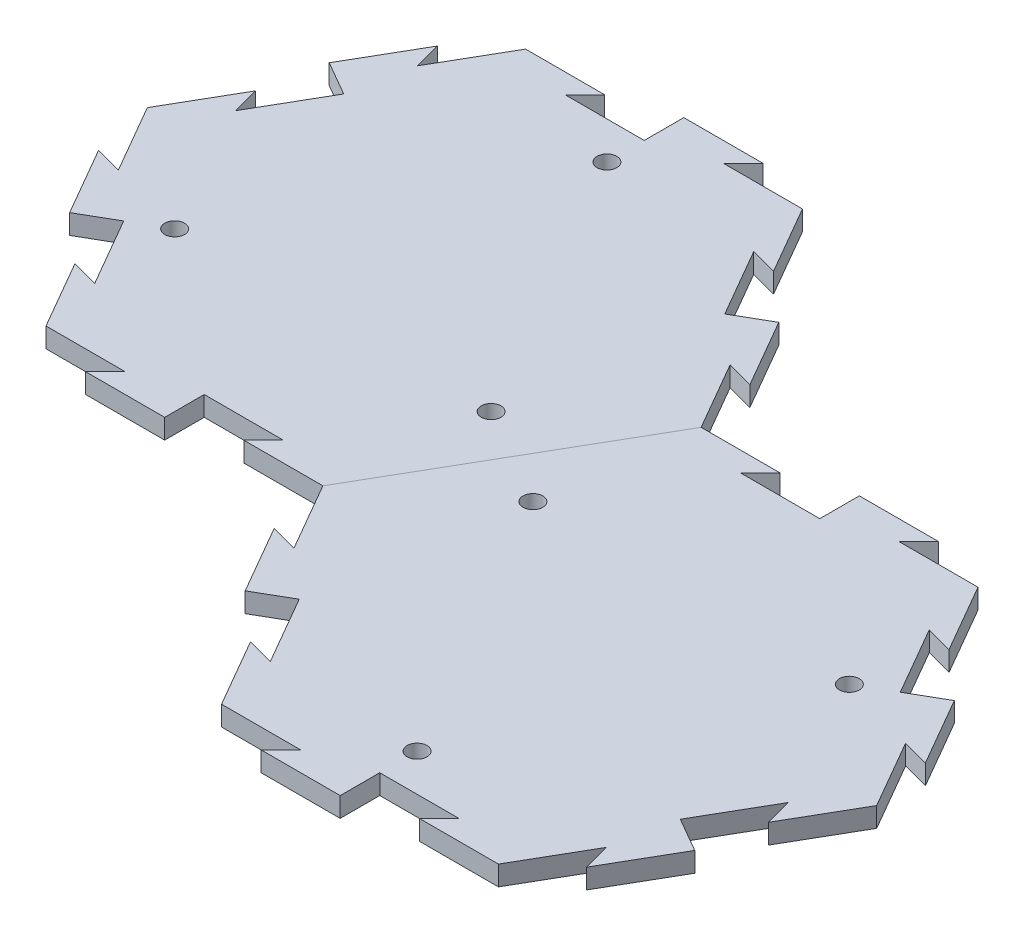
from build123d import *

# Parameters (mm, degrees)
BOSS_EXTRUDE1_DEPTH = 6.35
SKETCH9_R           = 3.175
CUT_EXTRUDE3_DEPTH  = 118.774954893
CIRPATTERN6_COUNT   = 3
CUT_EXTRUDE4_DEPTH  = 271.453350876
BOSS_EXTRUDE4_DEPTH = 6.35
CIRPATTERN7_COUNT   = 6
CUT_EXTRUDE5_DEPTH  = 271.453350876
BOSS_EXTRUDE5_DEPTH = 6.35
CIRPATTERN8_COUNT   = 6


with BuildPart() as part:
    # Sketch1 → Boss-Extrude1 (new body)
    with BuildSketch(Plane(origin=(0, 0, 0), x_dir=(1, 0, 0), z_dir=(0, 1, 0))):
        Polygon((88.9, 0), (44.45, 76.989658396), (-44.45, 76.989658396), (-88.9, 0), (-44.45, -76.989658396), (44.45, -76.989658396), align=None)
    extrude(amount=-BOSS_EXTRUDE1_DEPTH)

    # Sketch9 → Cut-Extrude3 (cut, through all)
    with BuildSketch(Plane(origin=(0, 0, 0), x_dir=(1, 0, 0), z_dir=(0, 1, 0))):
        with Locations((-50.8, -29.329393675)):
            Circle(SKETCH9_R)
    cut_extrude3 = extrude(amount=-CUT_EXTRUDE3_DEPTH, mode=Mode.SUBTRACT)

    # CirPattern6: Cut-Extrude3 ×3 about axis
    cirpattern6_axis = Axis((0, 0, 0), (0, 1, 0))
    for i in range(1, CIRPATTERN6_COUNT):
        add(cut_extrude3.rotate(cirpattern6_axis, i * 360 / CIRPATTERN6_COUNT), mode=Mode.SUBTRACT)


with BuildPart() as body_2:
    # Mirror3: mirrored copy
    add(part.part.mirror(Plane(origin=(44.45, -6.35, 76.989658396), x_dir=(-0.49999999999999495, 0, 0.8660254037844416), z_dir=(0.8660254037844416, 0, 0.49999999999999495))))

    # Sketch13 → Cut-Extrude5 (cut, through all)
    with BuildSketch(Plane(origin=(0, 0, 0), x_dir=(1, 0, 0), z_dir=(0, 1, 0))):
        Polygon((190.5, -21.997045256), (181.825738686, -19.672783942), (194.525738686, -41.669829198), (200.025, -38.494829198), align=None)
    cut_extrude5 = extrude(amount=-CUT_EXTRUDE5_DEPTH, mode=Mode.SUBTRACT)

    # Sketch14 → Boss-Extrude5 (add)
    with BuildSketch(Plane(origin=(0, 0, 0), x_dir=(1, 0, 0), z_dir=(0, 1, 0))):
        Polygon((200.025, -38.494829198), (205.524261314, -35.319829198), (218.224261314, -57.316874454), (209.55, -54.99261314), align=None)
    boss_extrude5 = extrude(amount=-BOSS_EXTRUDE5_DEPTH)

    # CirPattern8: Cut-Extrude5, Boss-Extrude5 ×6 about axis, 1 skipped
    cirpattern8_axis = Axis((133.35, 0, 76.989658396), (0, 1, 0))
    add([cut_extrude5.rotate(cirpattern8_axis, i * 360 / CIRPATTERN8_COUNT) for i in range(1, CIRPATTERN8_COUNT) if i not in (2,)], mode=Mode.SUBTRACT)
    add([boss_extrude5.rotate(cirpattern8_axis, i * 360 / CIRPATTERN8_COUNT) for i in range(1, CIRPATTERN8_COUNT) if i not in (2,)])


with BuildPart() as part_1:
    add(part.part)

    # Sketch10 → Cut-Extrude4 (cut, through all)
    with BuildSketch(Plane(origin=(0, 0, 0), x_dir=(1, 0, 0), z_dir=(0, 1, 0))):
        Polygon((57.15, 54.99261314), (48.475738686, 57.316874454), (61.175738686, 35.319829198), (66.675, 38.494829198), align=None)
    cut_extrude4 = extrude(amount=-CUT_EXTRUDE4_DEPTH, mode=Mode.SUBTRACT)

    # Sketch11 → Boss-Extrude4 (add)
    with BuildSketch(Plane(origin=(0, 0, 0), x_dir=(1, 0, 0), z_dir=(0, 1, 0))):
        Polygon((66.675, 38.494829198), (72.174261314, 41.669829198), (84.874261314, 19.672783942), (76.2, 21.997045256), align=None)
    boss_extrude4 = extrude(amount=-BOSS_EXTRUDE4_DEPTH)

    # CirPattern7: Cut-Extrude4, Boss-Extrude4 ×6 about axis, 1 skipped
    cirpattern7_axis = Axis((0, 0, 0), (0, 1, 0))
    add([cut_extrude4.rotate(cirpattern7_axis, i * 360 / CIRPATTERN7_COUNT) for i in range(1, CIRPATTERN7_COUNT) if i not in (5,)], mode=Mode.SUBTRACT)
    add([boss_extrude4.rotate(cirpattern7_axis, i * 360 / CIRPATTERN7_COUNT) for i in range(1, CIRPATTERN7_COUNT) if i not in (5,)])


solid = Compound([body_2.part, part_1.part])
